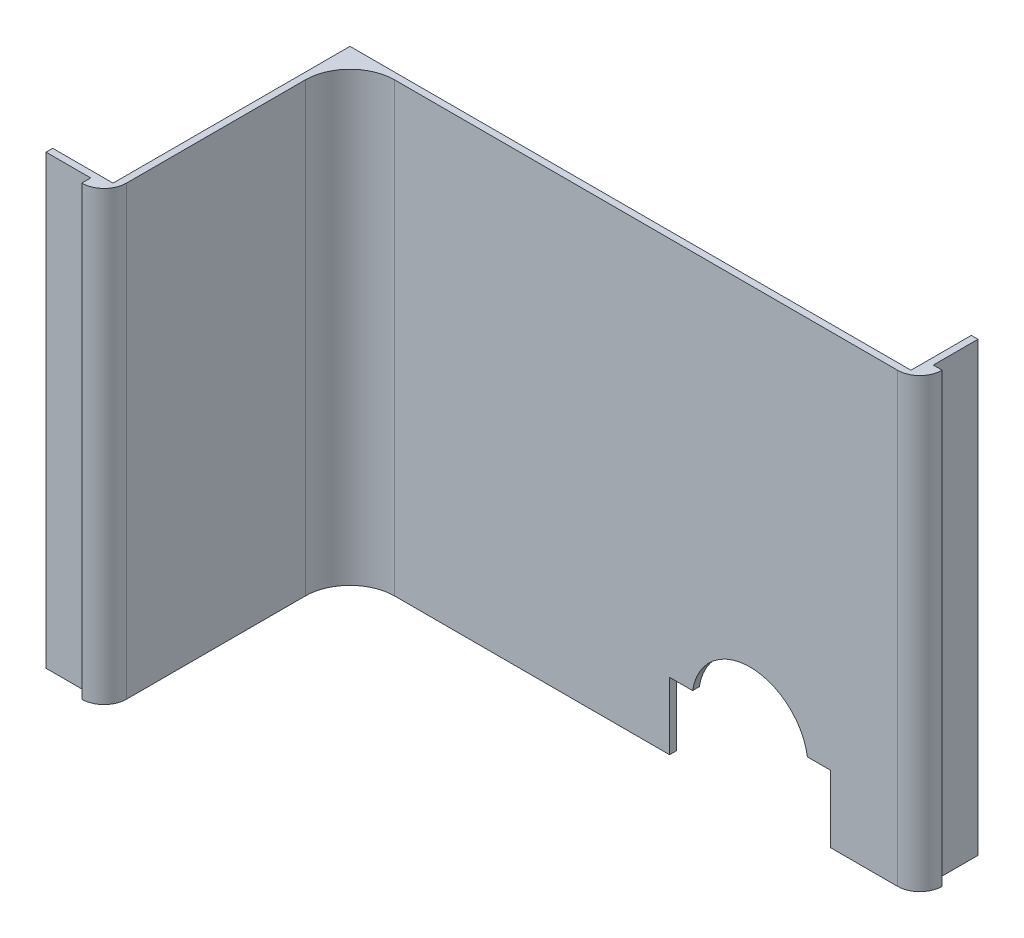
from build123d import *

# Parameters (mm, degrees)
EXTRUDE_1_DEPTH     = 100
CUT_EXTRUDE_1_DEPTH = 16


with BuildPart() as part:
    # Эскиз1 → Бобышка-Вытянуть1 (new body)
    with BuildSketch(Plane(origin=(0, 0, 0), x_dir=(1, 0, 0), z_dir=(0, 1, 0))):
        with BuildLine():
            Line((0, 0), (-112.5, 0))
            ThreePointArc((-112.5, 0), (-119.571067812, -2.928932188), (-122.5, -10))
            Line((-122.5, -10), (-122.5, -50))
            ThreePointArc((-122.5, -50), (-123.964466094, -53.535533906), (-127.5, -55))
            Line((-127.5, -55), (-127.5, -53))
            Line((-127.5, -53), (-137.5, -53))
            Line((-137.5, -53), (-137.5, -51.5))
            Line((-137.5, -51.5), (-124, -51.5))
            Line((-124, -51.5), (-124, 1.5))
            Line((-124, 1.5), (1.5, 1.5))
            Line((1.5, 1.5), (1.5, 15))
            Line((1.5, 15), (3, 15))
            Line((3, 15), (3, 5))
            Line((3, 5), (5, 5))
            ThreePointArc((5, 5), (3.535533906, 1.464466094), (0, 0))
        make_face()
    extrude(amount=EXTRUDE_1_DEPTH)

    # Эскиз4 → Вырез-Вытянуть1 (cut, through all)
    with BuildSketch(Plane.XY):
        with BuildLine():
            Line((-15, 0), (-51, 0))
            Line((-51, 0), (-51, 15))
            Line((-51, 15), (-45.845232579, 15))
            ThreePointArc((-45.845232579, 15), (-32.998579553, 25.999999922), (-20.154330668, 14.997192881))
            Line((-20.154330668, 14.997192881), (-15, 14.997192881))
            Line((-15, 14.997192881), (-15, 0))
        make_face()
    extrude(amount=-CUT_EXTRUDE_1_DEPTH, mode=Mode.SUBTRACT)


solid = part.part
